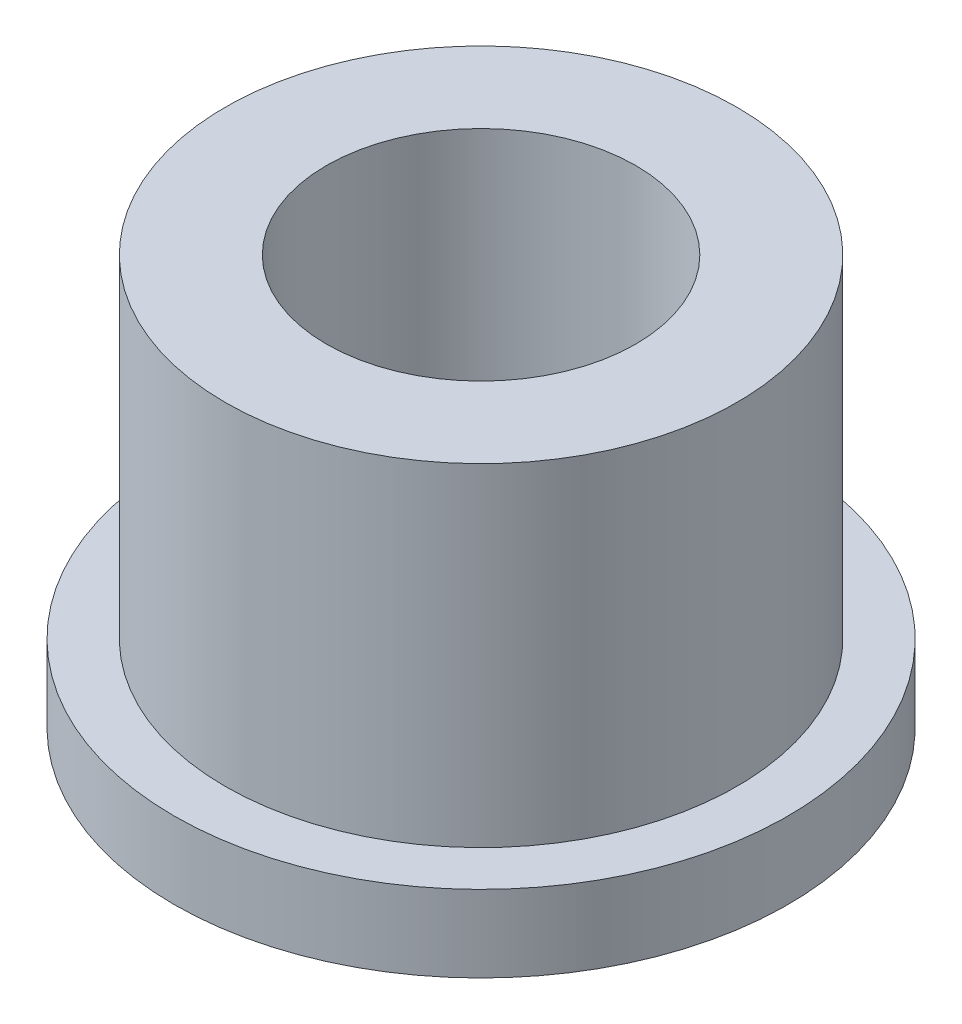
from build123d import *

# Parameters (mm, degrees)
SKETCH2_R           = 3.96875
SKETCH2_R_2         = 2.4003
BOSS_EXTRUDE1_DEPTH = 6.35
SKETCH3_R           = 4.7625
SKETCH3_R_2         = 3.96875
BOSS_EXTRUDE2_DEPTH = 1.190625


with BuildPart() as part:
    # Sketch2 → Boss-Extrude1 (new body)
    with BuildSketch(Plane(origin=(0, 0, 0), x_dir=(1, 0, 0), z_dir=(0, 1, 0))):
        Circle(SKETCH2_R)
        Circle(SKETCH2_R_2, mode=Mode.SUBTRACT)
    extrude(amount=BOSS_EXTRUDE1_DEPTH)

    # Sketch3 → Boss-Extrude2 (add)
    with BuildSketch(Plane(origin=(0, 0, 0), x_dir=(1, 0, 0), z_dir=(0, 1, 0))):
        Circle(SKETCH3_R)
        Circle(SKETCH3_R_2, mode=Mode.SUBTRACT)
    extrude(amount=BOSS_EXTRUDE2_DEPTH)


solid = part.part
